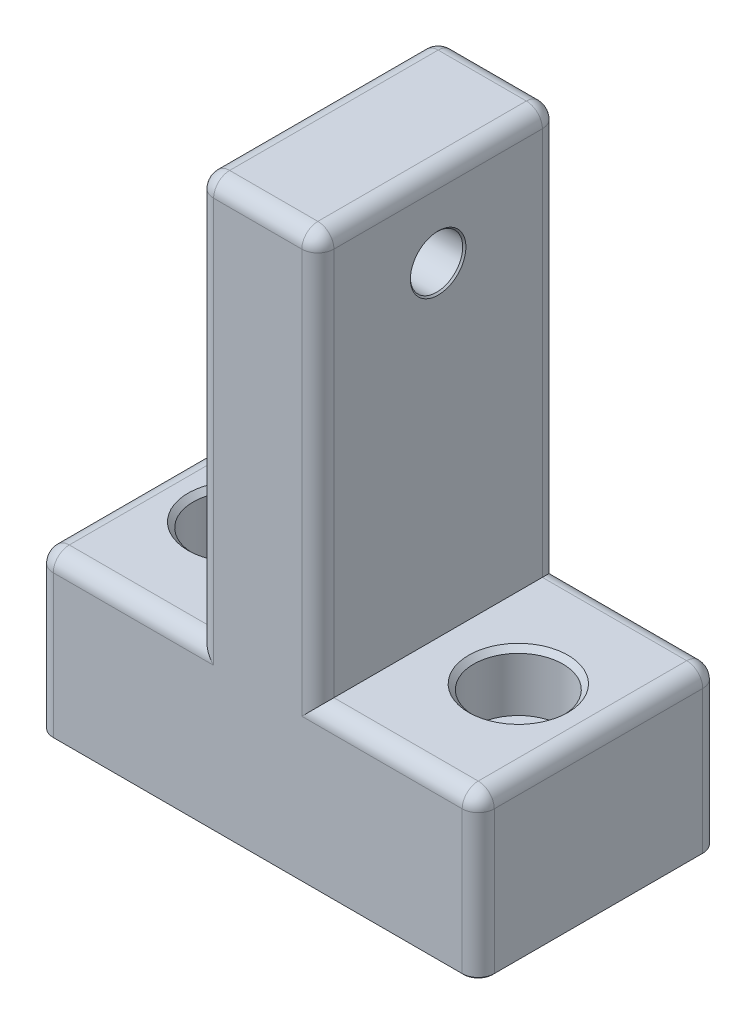
from build123d import *

# Parameters (mm, degrees)
BOSS_EXTRUDE1_DEPTH                           = 30
SKETCH2_R                                     = 3.2639
CUT_EXTRUDE1_DEPTH                            = 36
CBORE_FOR_1_4_SOCKET_HEAD_CAP_SCREW1_AT_COUNT = 2
CBORE_FOR_1_4_SOCKET_HEAD_CAP_SCREW1_AT_PITCH = 35
SKETCH7_W                                     = 15
SKETCH7_H                                     = 6.5
BOSS_EXTRUDE2_DEPTH                           = 3
FILLET1_R                                     = 2
CHAMFER1_SIZE                                 = 0.2


with BuildPart() as part:
    # Sketch1 → Boss-Extrude1 (new body)
    with BuildSketch(Plane.XY):
        Polygon((20, 0), (0, 0), (0, 50.45), (-15, 50.45), (-15, 0), (-35, 0), (-35, -20), (20, -20), align=None)
    extrude(amount=BOSS_EXTRUDE1_DEPTH)

    # Sketch2 → Cut-Extrude1 (cut, through all)
    with BuildSketch(Plane(origin=(0, 0, 0), x_dir=(0, 0, -1), z_dir=(1, 0, 0))):
        with Locations((-15, 40.45)):
            Circle(SKETCH2_R)
    extrude(amount=-CUT_EXTRUDE1_DEPTH, mode=Mode.SUBTRACT)

    # Sketch5 → CBORE for 1/4 Socket Head Cap Screw1 (revolve, cut)
    with BuildSketch(Plane(origin=(-25, 0, 15), x_dir=(0, 0, 1), z_dir=(1, 0, 0))):
        Polygon((0, 0), (0, 20), (3.8989, 20), (3.2639, 19.365), (3.2639, 7.984998), (3.8989, 7.349998), (5.55625, 7.349998), (5.55625, 0.635), (6.19125, 0), align=None)
    cbore_for_1_4_socket_head_cap_screw1 = revolve(axis=Axis((-25, 6.35, 15), (0, -1, 0)), mode=Mode.SUBTRACT)

    # CBORE for 1/4 Socket Head Cap Screw1 at: CBORE for 1/4 Socket Head Cap Screw1 ×2
    with Locations(*[(i * CBORE_FOR_1_4_SOCKET_HEAD_CAP_SCREW1_AT_PITCH, 0, 0) for i in range(1, CBORE_FOR_1_4_SOCKET_HEAD_CAP_SCREW1_AT_COUNT)]):
        add(cbore_for_1_4_socket_head_cap_screw1, mode=Mode.SUBTRACT)

    # Sketch7 → Boss-Extrude2 (add)
    with BuildSketch(Plane.XZ.offset(20)):
        with Locations((-7.5, 15)):
            Rectangle(SKETCH7_W, SKETCH7_H)
    extrude(amount=BOSS_EXTRUDE2_DEPTH)

    # Fillet1
    fillet1_edges = [part.edges().sort_by_distance(p)[0] for p in [
        (-35, -10, 30),
        (-15, 25.225, 0),
        (-7.5, 50.45, 0),
        (0, 25.225, 0),
        (10, 0, 0),
        (20, -10, 0),
        (-35, -10, 0),
        (-25, 0, 0),
        (-15, 50.45, 15),
        (0, 50.45, 15),
        (20, 0, 15),
        (-35, 0, 15),
        (20, -10, 30),
        (10, 0, 30),
        (0, 25.225, 30),
        (-7.5, 50.45, 30),
        (-15, 25.225, 30),
        (-25, 0, 30),
        (-15, -21.5, 11.75),
        (0, -21.5, 11.75),
        (0, -21.5, 18.25),
        (-15, -21.5, 18.25),
    ]]
    fillet(fillet1_edges, radius=FILLET1_R)

    # Chamfer1
    chamfer1_edges = [part.edges().sort_by_distance(p)[0] for p in [
        (-35, -20, 15),
        (-34.414213562, -20, 29.414213562),
        (-34.414213562, -20, 0.585786438),
        (19.414213562, -20, 0.585786438),
        (19.414213562, -20, 29.414213562),
        (-15, 40.45, 18.2639),
        (0, 40.45, 18.2639),
        (0, -23, 15),
        (-7.5, -23, 11.75),
        (-7.5, -23, 18.25),
        (-15, -23, 15),
        (-14.414213562, -23, 12.335786438),
        (-14.414213562, -23, 17.664213562),
        (-0.585786438, -23, 17.664213562),
        (-0.585786438, -23, 12.335786438),
        (-7.5, -20, 0),
        (-7.5, -20, 30),
        (20, -20, 15),
    ]]
    chamfer(chamfer1_edges, length=CHAMFER1_SIZE)


solid = part.part
